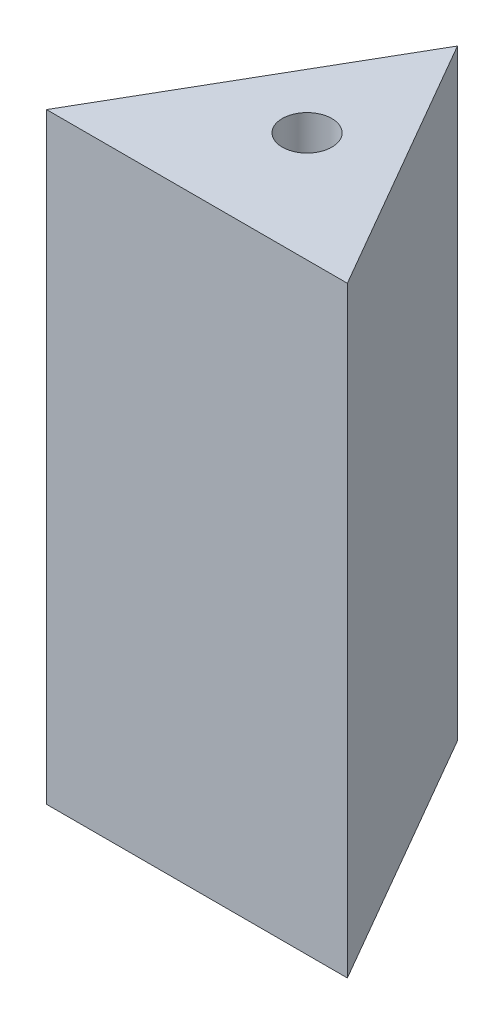
from build123d import *

# Parameters (mm, degrees)
EXTRUDE_1_DEPTH        = 40
HOLE_WIZARD_M4_1_D     = 3.3
HOLE_WIZARD_M4_1_DEPTH = 10.1
HOLE_WIZARD_M4_1_TIP   = 0.991420021
HOLE_WIZARD_M4_2_D     = 3.3
HOLE_WIZARD_M4_2_DEPTH = 10.1
HOLE_WIZARD_M4_2_TIP   = 0.991420021


with BuildPart() as part:
    # 草图1 → 凸台-拉伸1 (new body)
    with BuildSketch(Plane(origin=(0, 0, 0), x_dir=(1, 0, 0), z_dir=(0, 1, 0))):
        Polygon((0, 0), (20, 0), (10, 17.320508076), align=None)
    extrude(amount=EXTRUDE_1_DEPTH)

    # M4 螺纹孔1
    with Locations(Plane(origin=(0, 0, 0), x_dir=(-1, 0, 0), z_dir=(0, -1, 0))):
        with Locations((-10, 7.320508076)):
            Hole(HOLE_WIZARD_M4_1_D / 2, depth=HOLE_WIZARD_M4_1_DEPTH)
            with Locations((0, 0, -(HOLE_WIZARD_M4_1_DEPTH + HOLE_WIZARD_M4_1_TIP / 2))):  # 118° drill point
                Cone(0, HOLE_WIZARD_M4_1_D / 2, HOLE_WIZARD_M4_1_TIP, mode=Mode.SUBTRACT)

    # M4 螺纹孔2
    with Locations(Plane(origin=(0, 40, 0), x_dir=(1, 0, 0), z_dir=(0, 1, 0))):
        with Locations((10, 7.320508076)):
            Hole(HOLE_WIZARD_M4_2_D / 2, depth=HOLE_WIZARD_M4_2_DEPTH)
            with Locations((0, 0, -(HOLE_WIZARD_M4_2_DEPTH + HOLE_WIZARD_M4_2_TIP / 2))):  # 118° drill point
                Cone(0, HOLE_WIZARD_M4_2_D / 2, HOLE_WIZARD_M4_2_TIP, mode=Mode.SUBTRACT)


solid = part.part
